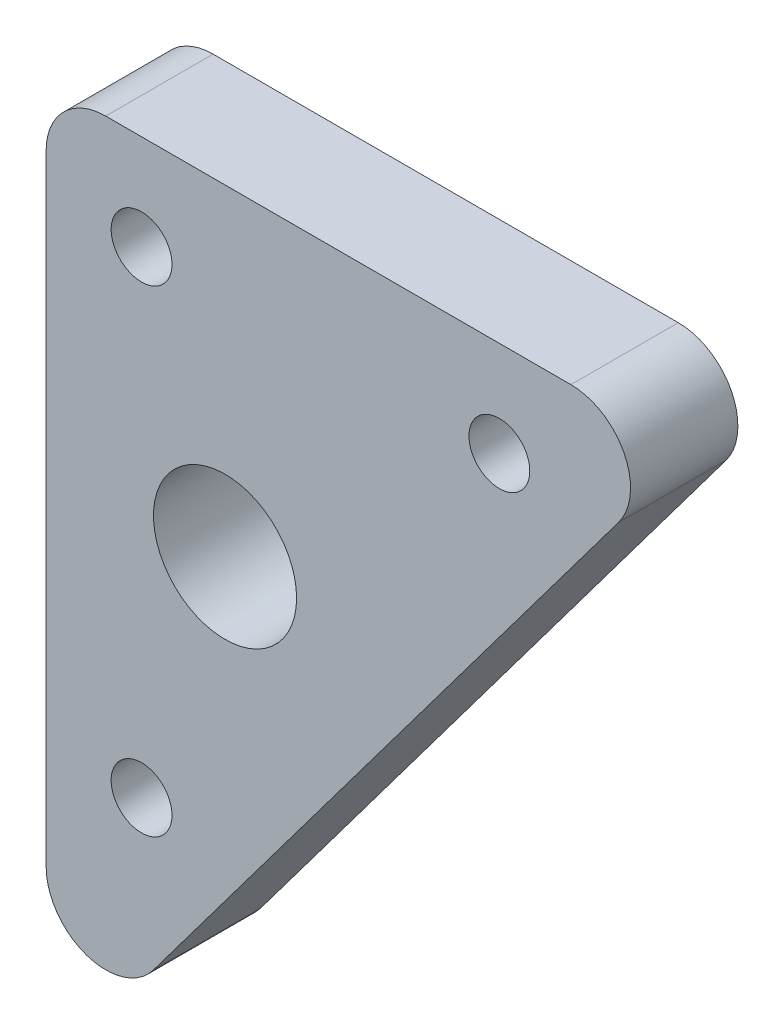
from build123d import *

# Parameters (mm, degrees)
SKETCH_1_R      = 2.55
SKETCH_1_R_2    = 6
EXTRUDE_1_DEPTH = 9
FILLET_1_R      = 5


with BuildPart() as part:
    # 草图1 → 凸台-拉伸1 (new body)
    with BuildSketch(Plane.XY):
        Polygon((-19.728395062, 20.160493827), (34.271604938, 20.160493827), (-19.728395062, -51.839506173), align=None)
        with Locations((-11.728395062, 12.160493827)):
            Circle(SKETCH_1_R, mode=Mode.SUBTRACT)
        with Locations((18.271604938, 12.160493827)):
            Circle(SKETCH_1_R, mode=Mode.SUBTRACT)
        with Locations((-11.728395062, -27.839506173)):
            Circle(SKETCH_1_R, mode=Mode.SUBTRACT)
        with Locations((-4.728395062, -6.839506173)):
            Circle(SKETCH_1_R_2, mode=Mode.SUBTRACT)
    extrude(amount=EXTRUDE_1_DEPTH)

    # 圆角1
    fillet_1_edges = [part.edges().sort_by_distance(p)[0] for p in [
        (-19.728395062, 20.160493827, 4.5),
        (34.271604938, 20.160493827, 4.5),
        (-19.728395062, -51.839506173, 4.5),
    ]]
    fillet(fillet_1_edges, radius=FILLET_1_R)


solid = part.part
